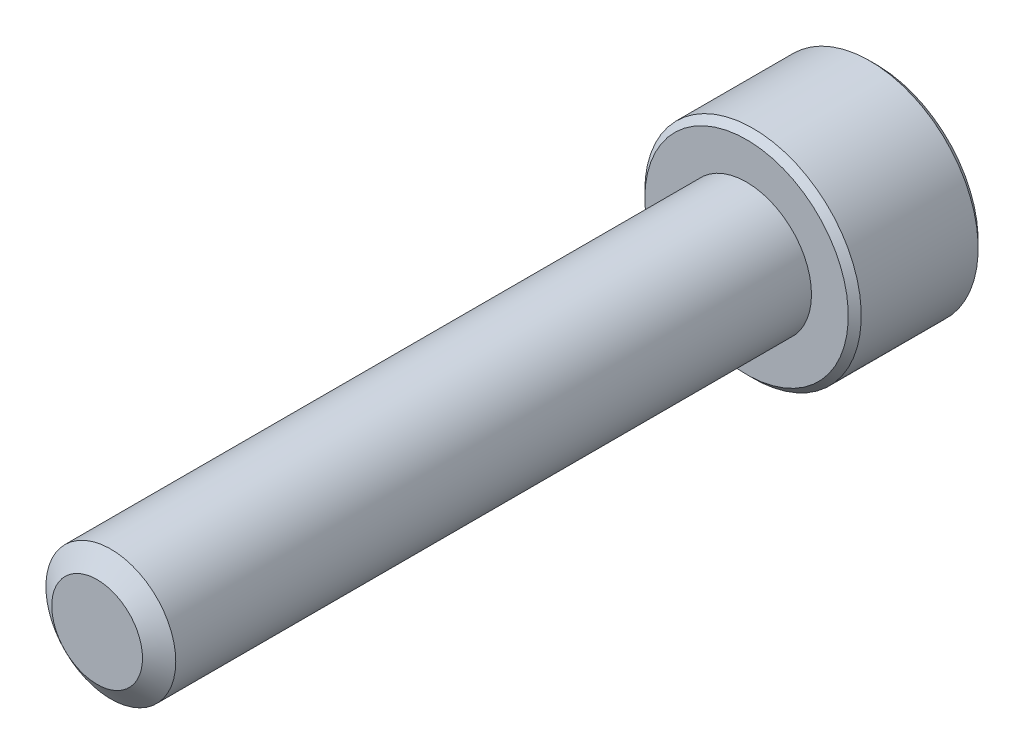
from build123d import *

# Parameters (mm, degrees)
SKETCH1_R          = 3
EXTRUDE1_DEPTH     = 30
SKETCH6_R          = 5
EXTRUDE2_DEPTH     = 6
CUT_EXTRUDE1_DEPTH = 3.75
CHAMFER1_SIZE      = 0.3


with BuildPart() as part:
    # Sketch1 → Extrude1 (new body)
    with BuildSketch(Plane.XY):
        Circle(SKETCH1_R)
    extrude(amount=-EXTRUDE1_DEPTH)

    # Sketch4 → Cut-Revolve1 (revolve, cut)
    with BuildSketch(Plane(origin=(0, 0, 0), x_dir=(0, 0, -1), z_dir=(1, 0, 0))):
        Polygon((0.632650852, 3), (0, 2.096480947), (0, 3), align=None)
    revolve(axis=Axis((0, 0, 0), (0, 0, -1)), mode=Mode.SUBTRACT)

    # Sketch6 → Extrude2 (add)
    with BuildSketch(Plane(origin=(0, 0, -30), x_dir=(-1, 0, 0), z_dir=(0, 0, -1))):
        Circle(SKETCH6_R)
    extrude(amount=EXTRUDE2_DEPTH)

    # Sketch7 → Cut-Extrude1 (cut)
    with BuildSketch(Plane(origin=(0, 0, -36), x_dir=(-1, 0, 0), z_dir=(0, 0, -1))):
        Polygon((0, 2.886751346), (-2.5, 1.443375673), (-2.5, -1.443375673), (0, -2.886751346), (2.5, -1.443375673), (2.5, 1.443375673), align=None)
    extrude(amount=-CUT_EXTRUDE1_DEPTH, mode=Mode.SUBTRACT)

    # Cut-Extrude2 cone 1 section (through the dimple's axis) → Cut-Extrude2 (revolve, cut)
    with BuildSketch(Plane(origin=(0, 0, -36), x_dir=(0, 1, 0), z_dir=(1, 0, 0))):
        Polygon((0, 0), (2.886751346, 0), (0, 2.886751346), align=None)
    revolve(axis=Axis((0, 0, -36), (0, 0, 1)), mode=Mode.SUBTRACT)

    # Chamfer1
    chamfer1_edges = [part.edges().sort_by_distance(p)[0] for p in [
        (5, 0, -36),
        (5, 0, -30),
    ]]
    chamfer(chamfer1_edges, length=CHAMFER1_SIZE)

    # Sketch10 → Revolve1 (revolve)
    with BuildSketch(Plane(origin=(0, 0, 0), x_dir=(0, 0, -1), z_dir=(1, 0, 0))):
        Polygon((30, 3), (30, 0), (28.507359313, 0), (29.75, 3), align=None)
    revolve(axis=Axis((0, 0, -30), (0, 0, 1)))


solid = part.part
